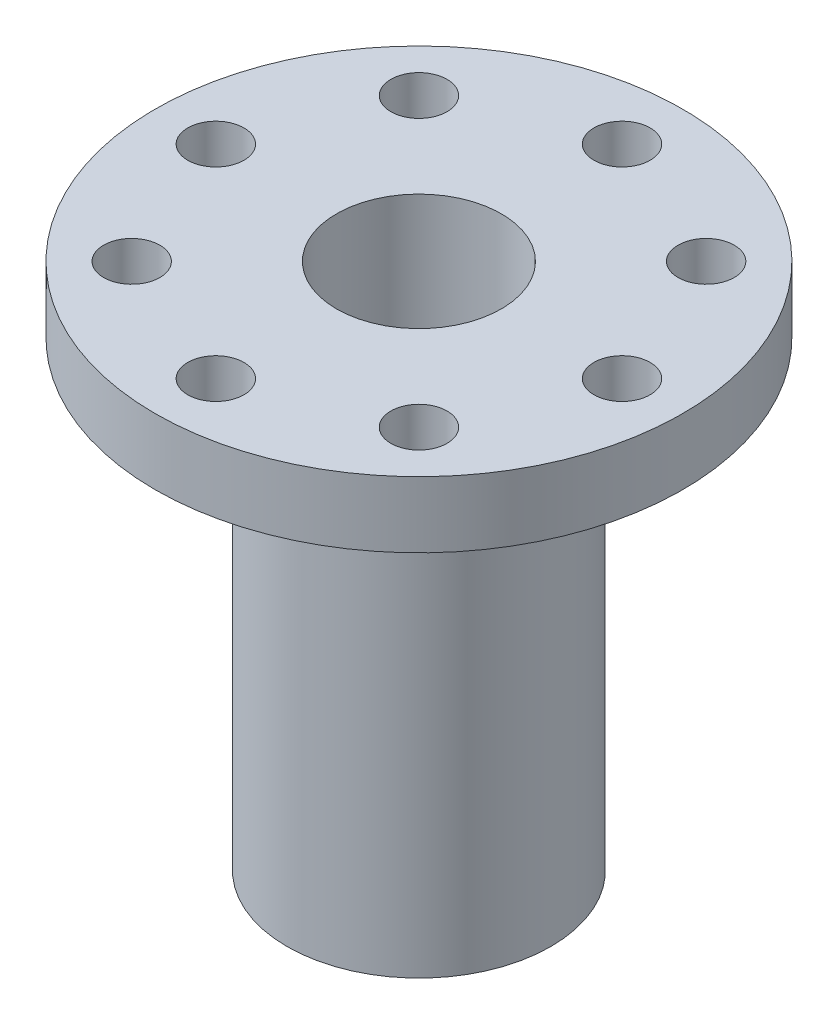
from build123d import *

# Parameters (mm, degrees)
SKETCH1_R                 = 12.7
BOSS_EXTRUDE1_DEPTH       = 3.175
SKETCH2_R                 = 6.35
BOSS_EXTRUDE2_DEPTH       = 22.225
SKETCH3_R                 = 3
CUT_EXTRUDE1_DEPTH        = 3.175
SKETCH4_R                 = 3.96875
CUT_EXTRUDE2_DEPTH        = 19.05
CUT_EXTRUDE3_REACH        = 8.35
SKETCH5_R                 = 1.6
F_6_32_TAPPED_HOLE1_D     = 2.7051
F_6_32_TAPPED_HOLE1_DEPTH = 3.175


with BuildPart() as part:
    # Sketch1 → Boss-Extrude1 (new body)
    with BuildSketch(Plane(origin=(0, 0, 0), x_dir=(1, 0, 0), z_dir=(0, 1, 0))):
        Circle(SKETCH1_R)
    extrude(amount=BOSS_EXTRUDE1_DEPTH)

    # Sketch2 → Boss-Extrude2 (add)
    with BuildSketch(Plane(origin=(0, 0, 0), x_dir=(1, 0, 0), z_dir=(0, 1, 0))):
        Circle(SKETCH2_R)
    extrude(amount=-BOSS_EXTRUDE2_DEPTH)

    # Sketch3 → Cut-Extrude1 (cut)
    with BuildSketch(Plane.XZ.offset(22.225)):
        Circle(SKETCH3_R)
    extrude(amount=-CUT_EXTRUDE1_DEPTH, mode=Mode.SUBTRACT)

    # Sketch4 → Cut-Extrude2 (cut)
    with BuildSketch(Plane(origin=(0, 3.175, 0), x_dir=(1, 0, 0), z_dir=(0, 1, 0))):
        Circle(SKETCH4_R)
    extrude(amount=-CUT_EXTRUDE2_DEPTH, mode=Mode.SUBTRACT)

    # Sketch5 → Cut-Extrude3 (cut, up to next)
    with BuildSketch(Plane(origin=(0, -15.875, 0), x_dir=(1, 0, 0), z_dir=(0, 1, 0)), mode=Mode.PRIVATE) as cut_extrude3_sk1:
        Circle(SKETCH5_R)
    cut_extrude3_tool1 = extrude(cut_extrude3_sk1.sketch, amount=-CUT_EXTRUDE3_REACH, mode=Mode.PRIVATE) & part.part
    add(cut_extrude3_tool1.solids().sort_by_distance((0, -15.875, 0))[0], mode=Mode.SUBTRACT)

    # #6-32 Tapped Hole1
    with Locations(Plane(origin=(0, 3.175, 0), x_dir=(-1, 0, 0), z_dir=(0, 1, 0))):
        with Locations((0, -9.779), (-6.914797213, -6.914797213), (-9.779, 0), (-6.914797213, 6.914797213), (0, 9.779), (6.914797213, 6.914797213), (9.779, 0), (6.914797213, -6.914797213)):
            Hole(F_6_32_TAPPED_HOLE1_D / 2, depth=F_6_32_TAPPED_HOLE1_DEPTH)


solid = part.part
